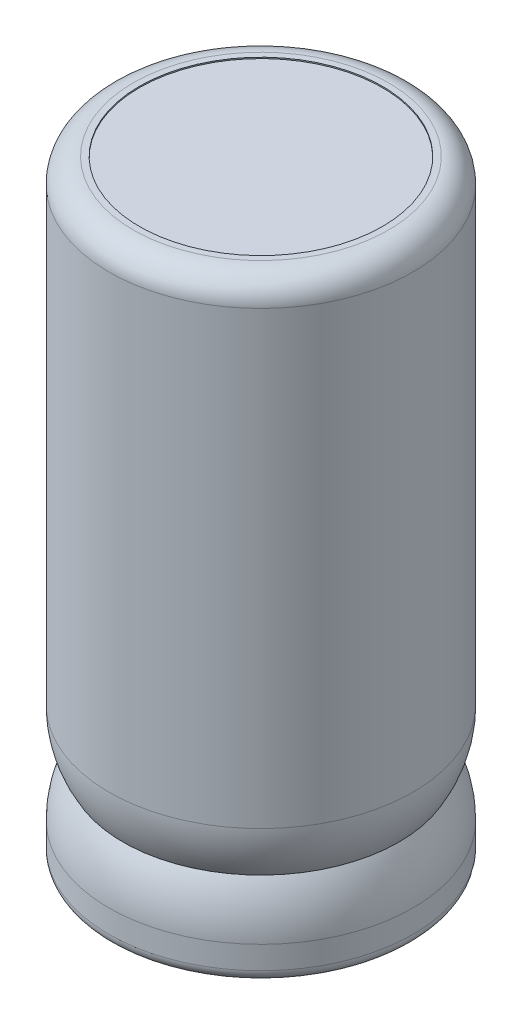
from build123d import *

# Parameters (mm, degrees)
SKETCH2_R           = 0.5
BOSS_EXTRUDE1_DEPTH = 3.5


with BuildPart() as part:
    # Sketch1 → Base-Revolve (revolve)
    with BuildSketch(Plane.XY):
        with BuildLine():
            Line((-6.35, 0.1), (3.65, 0.1))
            Line((3.65, 0.1), (3.65, 0))
            Line((3.65, 0), (5.15, 0))
            ThreePointArc((5.15, 0), (5.857106781, 0.292893219), (6.15, 1))
            Line((6.15, 1), (6.15, 2.88))
            ThreePointArc((6.15, 2.88), (5.858311082, 5.020546719), (5.004514935, 7.005))
            ThreePointArc((5.004514935, 7.005), (5.858311082, 8.989453281), (6.15, 11.13))
            Line((6.15, 11.13), (6.15, 48.2))
            ThreePointArc((6.15, 48.2), (5.564213562, 49.614213562), (4.15, 50.2))
            Line((4.15, 50.2), (3.65, 50.2))
            Line((3.65, 50.2), (3.65, 50.1))
            Line((3.65, 50.1), (-6.35, 50.1))
            Line((-6.35, 50.1), (-6.35, 0.1))
        make_face()
    revolve(axis=Axis((-6.35, 50.2, 0), (0, -1, 0)))

    # Sketch2 → Boss-Extrude1 (add)
    with BuildSketch(Plane.XZ.offset(-0.1)):
        Circle(SKETCH2_R)
        with Locations((-12.7, 0)):
            Circle(SKETCH2_R)
    extrude(amount=BOSS_EXTRUDE1_DEPTH)


solid = part.part
